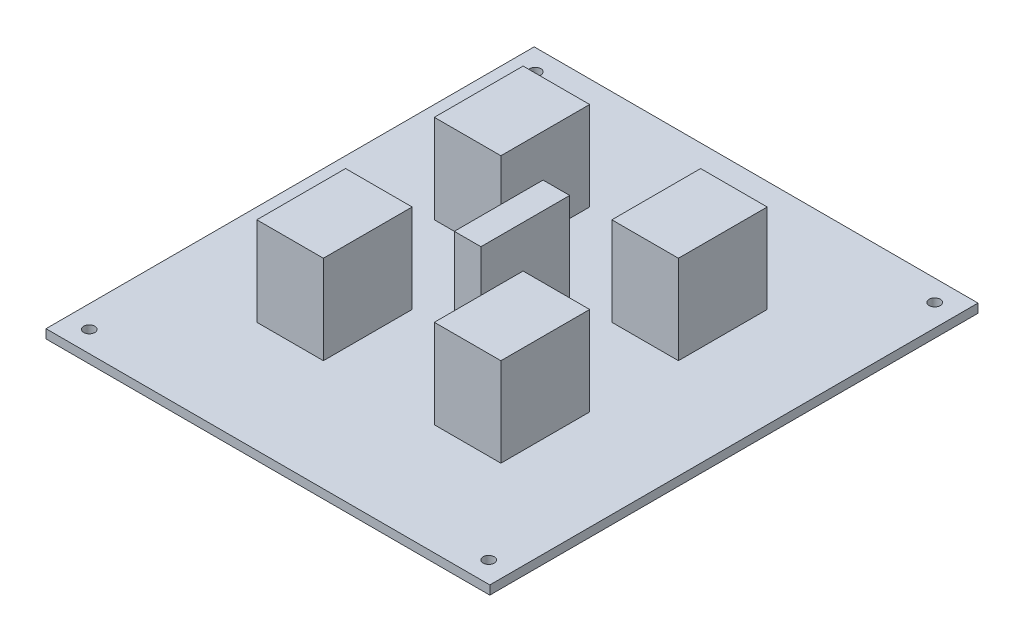
from build123d import *

# Parameters (mm, degrees)
SKETCH2_W           = 100
SKETCH2_H           = 110
SKETCH2_R           = 1.25
BOSS_EXTRUDE1_DEPTH = 2
SKETCH3_W           = 15
SKETCH3_H           = 20
SKETCH3_W_2         = 6
BOSS_EXTRUDE2_DEPTH = 20


with BuildPart() as part:
    # Sketch2 → Boss-Extrude1 (new body)
    with BuildSketch(Plane(origin=(0, 0, 0), x_dir=(1, 0, 0), z_dir=(0, 1, 0))):
        Rectangle(SKETCH2_W, SKETCH2_H)
        with Locations((-45, 50.25)):
            Circle(SKETCH2_R, mode=Mode.SUBTRACT)
        with Locations((45, 50.25)):
            Circle(SKETCH2_R, mode=Mode.SUBTRACT)
        with Locations((45, -50.25)):
            Circle(SKETCH2_R, mode=Mode.SUBTRACT)
        with Locations((-45, -50.25)):
            Circle(SKETCH2_R, mode=Mode.SUBTRACT)
    extrude(amount=BOSS_EXTRUDE1_DEPTH)

    # Sketch3 → Boss-Extrude2 (add)
    with BuildSketch(Plane(origin=(0, 2, 0), x_dir=(1, 0, 0), z_dir=(0, 1, 0))):
        with Locations((-20, -20)):
            Rectangle(SKETCH3_W, SKETCH3_H)
        Rectangle(SKETCH3_W_2, SKETCH3_H)
        with Locations((-20, 20)):
            Rectangle(SKETCH3_W, SKETCH3_H)
        with Locations((20, 20)):
            Rectangle(SKETCH3_W, SKETCH3_H)
        with Locations((20, -20)):
            Rectangle(SKETCH3_W, SKETCH3_H)
    extrude(amount=BOSS_EXTRUDE2_DEPTH)


solid = part.part
